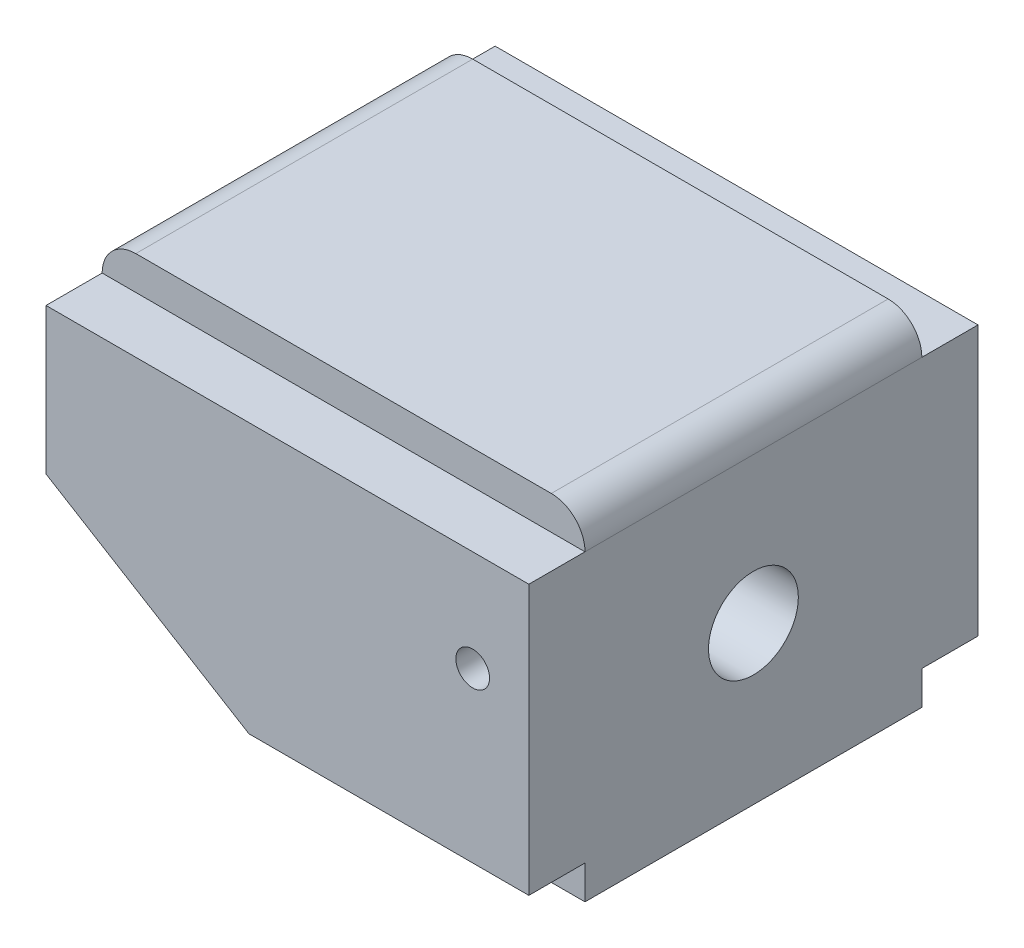
from build123d import *

# Parameters (mm, degrees)
EXTRUDE_1_DEPTH        = 15
FILLET_1_R             = 3
EXTRUDE_2_DEPTH        = 5
EXTRUDE_2_DEPTH_BACK   = 35
HOLE_WIZARD_M4_1_D     = 3
HOLE_WIZARD_M4_2_D     = 8
HOLE_WIZARD_M4_2_DEPTH = 13
HOLE_WIZARD_M4_2_TIP   = 2.403442476


with BuildPart() as part:
    # 스케치1 → 보스-돌출1 (new body, symmetric)
    with BuildSketch(Plane.XY):
        Polygon((0, 0), (-20, 0), (-43, 14), (-43, 30), (0, 30), align=None)
    extrude(amount=EXTRUDE_1_DEPTH, both=True)

    # 필렛1
    fillet_1_edges = [part.edges().sort_by_distance(p)[0] for p in [
        (-43, 30, 0),
        (0, 30, 0),
    ]]
    fillet(fillet_1_edges, radius=FILLET_1_R)

    # 스케치2 → 보스-돌출2 (add, two sides)
    with BuildSketch(Plane.XY.offset(15)) as extrude_2_sk:
        Polygon((-43, 27), (0, 27), (0, 3), (-24.928571429, 3), (-43, 14), align=None)
    extrude(amount=EXTRUDE_2_DEPTH)
    extrude(extrude_2_sk.sketch, amount=-EXTRUDE_2_DEPTH_BACK)

    # M4 여유 구멍1 (through all)
    with Locations(Plane.XY.offset(20)):
        with Locations((-5, 18)):
            Hole(HOLE_WIZARD_M4_1_D / 2)

    # M4 여유 구멍2
    with Locations(Plane(origin=(0, 0, 0), x_dir=(0, 0, -1), z_dir=(1, 0, 0))):
        with Locations((0, 14)):
            Hole(HOLE_WIZARD_M4_2_D / 2, depth=HOLE_WIZARD_M4_2_DEPTH)
            with Locations((0, 0, -(HOLE_WIZARD_M4_2_DEPTH + HOLE_WIZARD_M4_2_TIP / 2))):  # 118° drill point
                Cone(0, HOLE_WIZARD_M4_2_D / 2, HOLE_WIZARD_M4_2_TIP, mode=Mode.SUBTRACT)


solid = part.part
